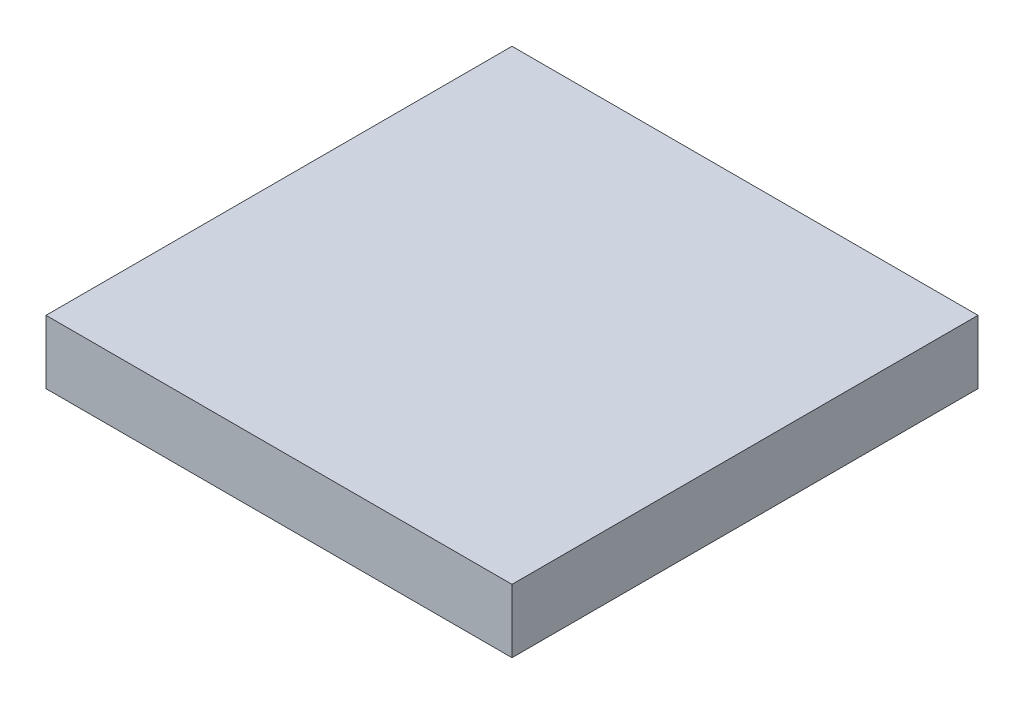
from build123d import *

# Parameters (mm, degrees)
SKETCH1_W           = 22
SKETCH1_H           = 22
BOSS_EXTRUDE1_DEPTH = 3


with BuildPart() as part:
    # Sketch1 → Boss-Extrude1 (new body)
    with BuildSketch(Plane(origin=(0, 0, 0), x_dir=(1, 0, 0), z_dir=(0, 1, 0))):
        with Locations((11, 11)):
            Rectangle(SKETCH1_W, SKETCH1_H)
    extrude(amount=BOSS_EXTRUDE1_DEPTH)


solid = part.part
